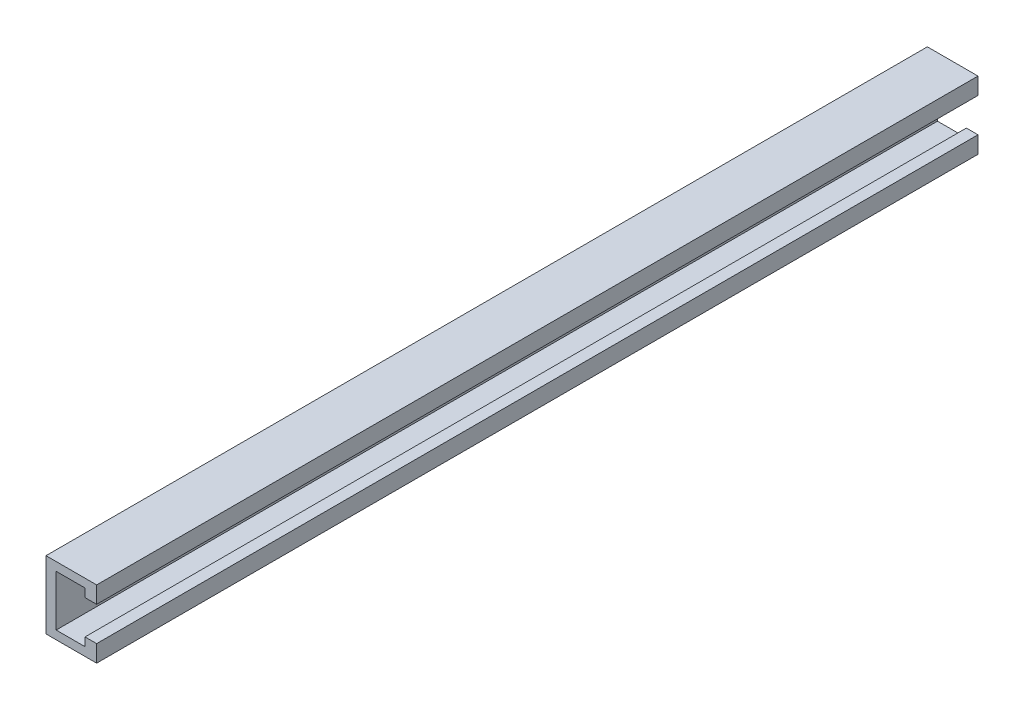
from build123d import *

# Parameters (mm, degrees)
BOSS_EXTRUDE1_DEPTH = 660.4
SKETCH2_R           = 6.35
CUT_EXTRUDE1_DEPTH  = 38.944489796


with BuildPart() as part:
    # Sketch1 → Boss-Extrude1 (new body)
    with BuildSketch(Plane.XY):
        Polygon((13.996027612, 10.491268563), (22.704599041, 10.491268563), (22.704599041, 23.093265306), (-15.239890755, 23.093265306), (-15.239890755, -27.706734694), (22.704599041, -27.706734694), (22.704599041, -15.006734694), (13.996027612, -15.006734694), (13.996027612, -21.356734694), (-7.619890755, -21.356734694), (-7.619890755, 16.743265306), (13.996027612, 16.743265306), align=None)
    extrude(amount=BOSS_EXTRUDE1_DEPTH)

    # Sketch2 → Cut-Extrude1 (cut, through all)
    with BuildSketch(Plane.ZY.offset(15.239890755)):
        with Locations((25.4, -2.306734694)):
            Circle(SKETCH2_R)
        with Locations((279.4, -2.306734694)):
            Circle(SKETCH2_R)
    extrude(amount=-CUT_EXTRUDE1_DEPTH, mode=Mode.SUBTRACT)


solid = part.part
